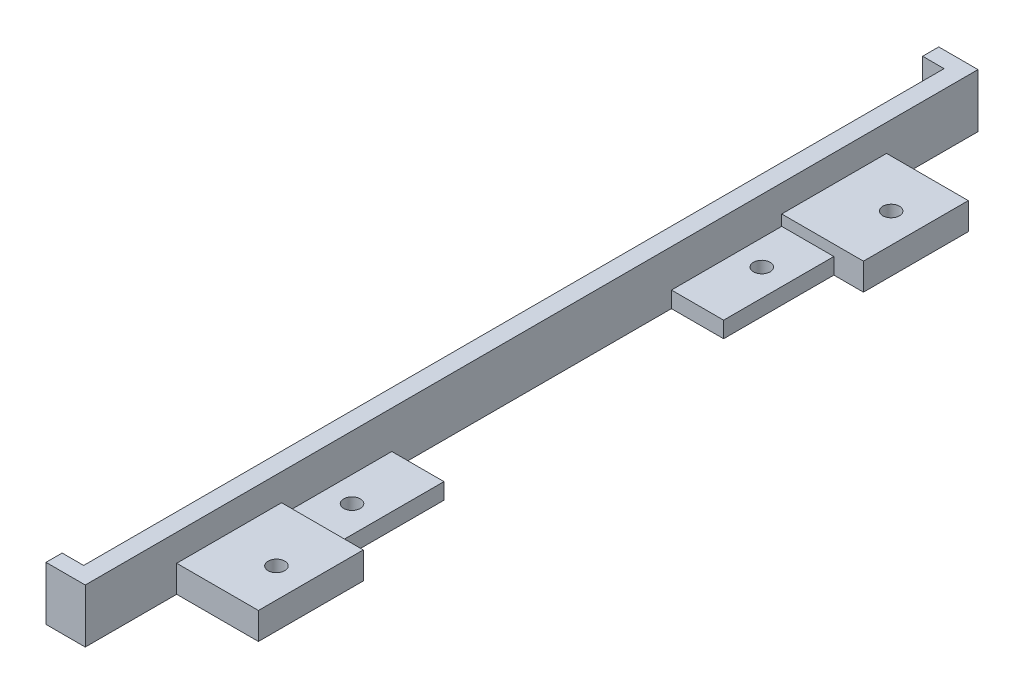
from build123d import *

# Parameters (mm, degrees)
SKETCH1_R           = 1.55
BOSS_EXTRUDE1_DEPTH = 10
SKETCH3_W           = 15.2
SKETCH3_H           = 132
CUT_EXTRUDE1_DEPTH  = 5
SKETCH4_W           = 9.7
SKETCH4_H           = 93
CUT_EXTRUDE2_DEPTH  = 2
CUT_EXTRUDE4_DEPTH  = 2.3


with BuildPart() as part:
    # Sketch1 → Boss-Extrude1 (new body)
    with BuildSketch(Plane(origin=(0, 0, 0), x_dir=(1, 0, 0), z_dir=(0, 1, 0))):
        Polygon((0, 0), (7.3, 0), (7.3, 17), (22.5, 17), (22.5, 36.5), (17, 36.5), (17, 57), (7.3, 57), (7.3, 109), (17, 109), (17, 129.5), (22.5, 129.5), (22.5, 149), (7.3, 149), (7.3, 166), (0, 166), (0, 163), (4, 163), (4, 3), (0, 3), align=None)
        with Locations((17, 25.85)):
            Circle(SKETCH1_R, mode=Mode.SUBTRACT)
        with Locations((12, 44.9)):
            Circle(SKETCH1_R, mode=Mode.SUBTRACT)
        with Locations((12, 121.1)):
            Circle(SKETCH1_R, mode=Mode.SUBTRACT)
        with Locations((17, 140.15)):
            Circle(SKETCH1_R, mode=Mode.SUBTRACT)
    extrude(amount=BOSS_EXTRUDE1_DEPTH)

    # Sketch3 → Cut-Extrude1 (cut)
    with BuildSketch(Plane(origin=(0, 10, 0), x_dir=(1, 0, 0), z_dir=(0, 1, 0))):
        with Locations((14.9, 83)):
            Rectangle(SKETCH3_W, SKETCH3_H)
    extrude(amount=-CUT_EXTRUDE1_DEPTH, mode=Mode.SUBTRACT)

    # Sketch4 → Cut-Extrude2 (cut)
    with BuildSketch(Plane(origin=(0, 5, 0), x_dir=(1, 0, 0), z_dir=(0, 1, 0))):
        with Locations((12.15, 83)):
            Rectangle(SKETCH4_W, SKETCH4_H)
    extrude(amount=-CUT_EXTRUDE2_DEPTH, mode=Mode.SUBTRACT)

    # Sketch5 → Cut-Extrude4 (cut)
    with BuildSketch(Plane.XZ):
        Polygon((19.75, -24.26228676), (19.75, -27.43771324), (17, -29.025426481), (14.25, -27.43771324), (14.25, -24.26228676), (17, -22.674573519), align=None)
        Polygon((14.25, -138.56228676), (14.25, -141.73771324), (17, -143.325426481), (19.75, -141.73771324), (19.75, -138.56228676), (17, -136.974573519), align=None)
    extrude(amount=-CUT_EXTRUDE4_DEPTH, mode=Mode.SUBTRACT)


solid = part.part
